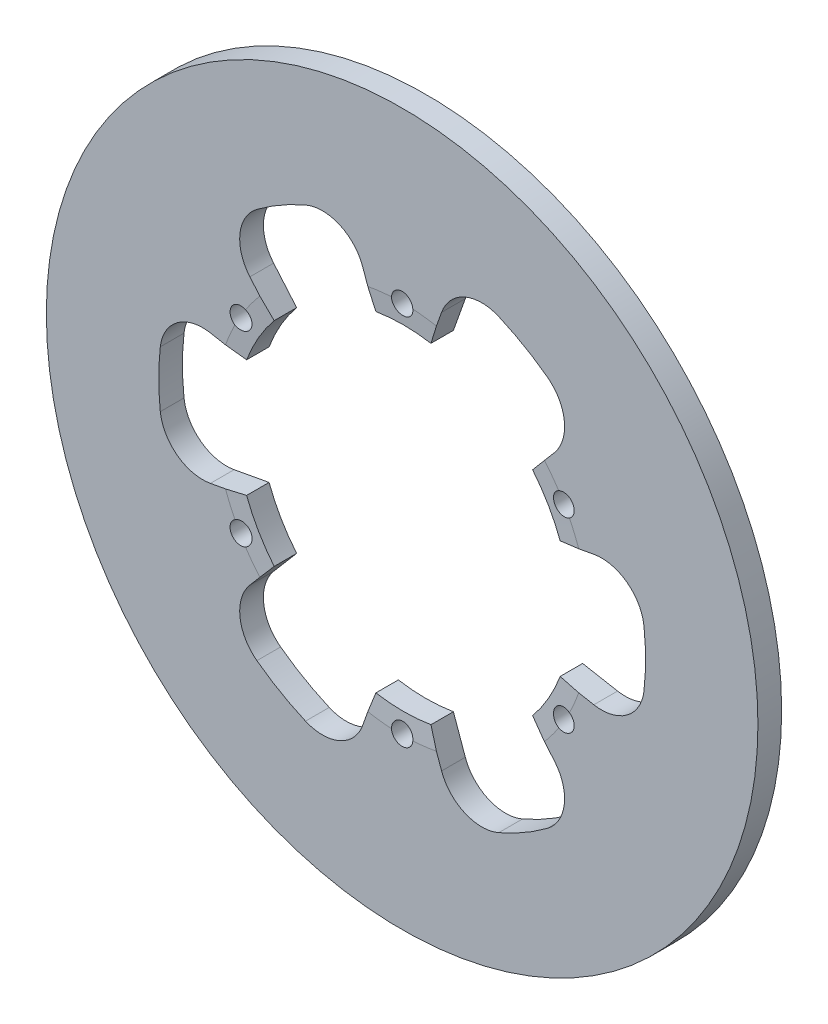
from build123d import *

# Parameters (mm, degrees)
BOSS_EXTRUDE1_DEPTH      = 4.445
BOSS_EXTRUDE1_DEPTH_BACK = 4.445
SKETCH1_R                = 133.35
SKETCH1_R_2              = 4


with BuildPart() as part:
    # Sketch1 → Boss-Extrude1 (new, two sides: drawn at the far end of the back side and taken through both)
    with BuildSketch(Plane.XY.offset(-BOSS_EXTRUDE1_DEPTH_BACK)):
        Circle(SKETCH1_R)
        with Locations((0, 69.85)):
            Circle(SKETCH1_R_2, mode=Mode.SUBTRACT)
        with Locations((60.491874454, 34.925)):
            Circle(SKETCH1_R_2, mode=Mode.SUBTRACT)
        with Locations((60.491874454, -34.925)):
            Circle(SKETCH1_R_2, mode=Mode.SUBTRACT)
        with Locations((0, -69.85)):
            Circle(SKETCH1_R_2, mode=Mode.SUBTRACT)
        with Locations((-60.491874454, -34.925)):
            Circle(SKETCH1_R_2, mode=Mode.SUBTRACT)
        with Locations((-60.491874454, 34.925)):
            Circle(SKETCH1_R_2, mode=Mode.SUBTRACT)
        with BuildLine():
            Line((14.785375278, 74.430875165), (10.324543782, 61.882634395))
            ThreePointArc((10.324543782, 61.882634395), (5.179957882, 62.523792914), (0, 62.738))
            ThreePointArc((0, 62.738), (-5.179957882, 62.523792914), (-10.324543782, 61.882634395))
            Line((-10.324543782, 61.882634395), (-14.785375278, 74.430875165))
            ThreePointArc((-14.785375278, 74.430875165), (-23.474698759, 83.741706154), (-36.210304588, 83.757843464))
            ThreePointArc((-36.210304588, 83.757843464), (-45.625, 79.024818095), (-54.431267912, 73.237965383))
            ThreePointArc((-54.431267912, 73.237965383), (-60.785095506, 62.200538548), (-57.06634108, 50.019948178))
            Line((-57.06634108, 50.019948178), (-48.429661548, 39.882634395))
            ThreePointArc((-48.429661548, 39.882634395), (-51.557214064, 35.747871573), (-54.332701783, 31.369))
            ThreePointArc((-54.332701783, 31.369), (-56.737171945, 26.775921341), (-58.75420533, 22))
            Line((-58.75420533, 22), (-71.851716358, 24.410926987))
            ThreePointArc((-71.851716358, 24.410926987), (-84.259794265, 21.541167606), (-90.641572499, 10.51987808))
            ThreePointArc((-90.641572499, 10.51987808), (-91.25, 0), (-90.641572499, -10.51987808))
            ThreePointArc((-90.641572499, -10.51987808), (-84.259794265, -21.541167606), (-71.851716358, -24.410926987))
            Line((-71.851716358, -24.410926987), (-58.75420533, -22))
            ThreePointArc((-58.75420533, -22), (-56.737171945, -26.775921341), (-54.332701783, -31.369))
            ThreePointArc((-54.332701783, -31.369), (-51.557214064, -35.747871573), (-48.429661548, -39.882634395))
            Line((-48.429661548, -39.882634395), (-57.06634108, -50.019948178))
            ThreePointArc((-57.06634108, -50.019948178), (-60.785095506, -62.200538548), (-54.431267912, -73.237965383))
            ThreePointArc((-54.431267912, -73.237965383), (-45.625, -79.024818095), (-36.210304588, -83.757843464))
            ThreePointArc((-36.210304588, -83.757843464), (-23.474698759, -83.741706154), (-14.785375278, -74.430875165))
            Line((-14.785375278, -74.430875165), (-10.324543782, -61.882634395))
            ThreePointArc((-10.324543782, -61.882634395), (-5.179957882, -62.523792914), (0, -62.738))
            ThreePointArc((0, -62.738), (5.179957882, -62.523792914), (10.324543782, -61.882634395))
            Line((10.324543782, -61.882634395), (14.785375278, -74.430875165))
            ThreePointArc((14.785375278, -74.430875165), (23.474698759, -83.741706154), (36.210304588, -83.757843464))
            ThreePointArc((36.210304588, -83.757843464), (45.625, -79.024818095), (54.431267912, -73.237965383))
            ThreePointArc((54.431267912, -73.237965383), (60.785095506, -62.200538548), (57.06634108, -50.019948178))
            Line((57.06634108, -50.019948178), (48.429661548, -39.882634395))
            ThreePointArc((48.429661548, -39.882634395), (51.557214064, -35.747871573), (54.332701783, -31.369))
            ThreePointArc((54.332701783, -31.369), (56.737171945, -26.775921341), (58.75420533, -22))
            Line((58.75420533, -22), (71.851716358, -24.410926987))
            ThreePointArc((71.851716358, -24.410926987), (84.259794265, -21.541167606), (90.641572499, -10.51987808))
            ThreePointArc((90.641572499, -10.51987808), (91.25, 0), (90.641572499, 10.51987808))
            ThreePointArc((90.641572499, 10.51987808), (84.259794265, 21.541167606), (71.851716358, 24.410926987))
            Line((71.851716358, 24.410926987), (58.75420533, 22))
            ThreePointArc((58.75420533, 22), (56.737171945, 26.775921341), (54.332701783, 31.369))
            ThreePointArc((54.332701783, 31.369), (51.557214064, 35.747871573), (48.429661548, 39.882634395))
            Line((48.429661548, 39.882634395), (57.06634108, 50.019948178))
            ThreePointArc((57.06634108, 50.019948178), (60.785095506, 62.200538548), (54.431267912, 73.237965383))
            ThreePointArc((54.431267912, 73.237965383), (45.625, 79.024818095), (36.210304588, 83.757843464))
            ThreePointArc((36.210304588, 83.757843464), (23.474698759, 83.741706154), (14.785375278, 74.430875165))
        make_face(mode=Mode.SUBTRACT)
    extrude(amount=BOSS_EXTRUDE1_DEPTH + BOSS_EXTRUDE1_DEPTH_BACK)

    # Sketch2 → Cut-Revolve1 (revolve, cut)
    with BuildSketch(Plane(origin=(0, 0, 0), x_dir=(0, 0, -1), z_dir=(1, 0, 0))):
        Polygon((0, 0), (-8.445, 133.35), (-26.557438236, 133.35), (-26.557438236, 0), align=None)
    revolve(axis=Axis((0, 0, 33.831792396), (0, 0, -1)), mode=Mode.SUBTRACT)


solid = part.part
